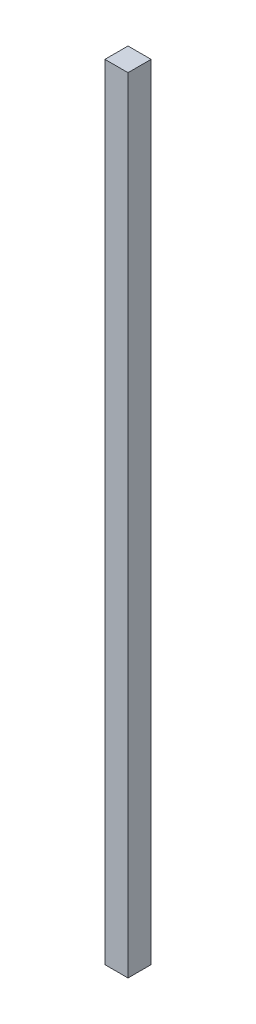
from build123d import *

# Parameters (mm, degrees)
SKETCH1_W           = 19.05
SKETCH1_H           = 19.05
BOSS_EXTRUDE1_DEPTH = 647


with BuildPart() as part:
    # Sketch1 → Boss-Extrude1 (new body)
    with BuildSketch(Plane(origin=(0, 0, 0), x_dir=(1, 0, 0), z_dir=(0, 1, 0))):
        with Locations((9.525, -9.525)):
            Rectangle(SKETCH1_W, SKETCH1_H)
    extrude(amount=BOSS_EXTRUDE1_DEPTH)


solid = part.part
